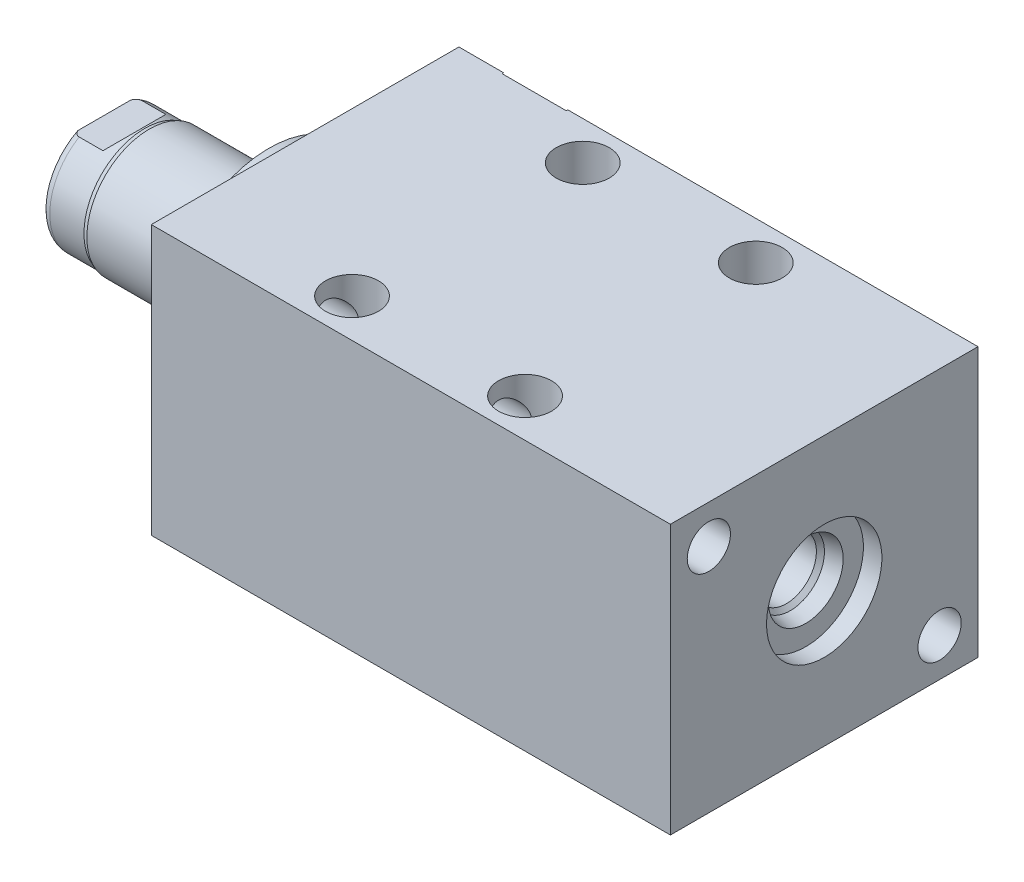
from build123d import *

# Parameters (mm, degrees)
SKETCH1_W          = 50.8
SKETCH1_H          = 44.45
EXTRUDE1_DEPTH     = 85.725
SKETCH5_R          = 17.4625
EXTRUDE2_DEPTH     = 5.969
SKETCH6_W          = 10.31875
SKETCH6_H          = 27.178
CUT_EXTRUDE4_DEPTH = 30.48
HOLE1_D            = 7.1374
HOLE1_DEPTH        = 85.725
HOLE2_D            = 8.7376
HOLE2_DEPTH        = 44.45
LPATTERN1_COUNT    = 2
LPATTERN1_PITCH    = 28.575


with BuildPart() as part:
    # Sketch1 → Extrude1 (new body)
    with BuildSketch(Plane(origin=(0, 0, 0), x_dir=(0, 0, -1), z_dir=(1, 0, 0))):
        Rectangle(SKETCH1_W, SKETCH1_H)
    extrude(amount=EXTRUDE1_DEPTH)

    # S2D0002 → Cut-Revolve1 (revolve, cut)
    with BuildSketch(Plane(origin=(0, 14.3002, 0), x_dir=(-1, 0, 0), z_dir=(0, 1, 0)), mode=Mode.PRIVATE) as cut_revolve1_sk:
        Polygon((-18.8849, -25.146), (-22.225, -25.146), (-22.225, -25.4), (-12.7, -25.4), (-12.7, -11.176), (-17.6784, -11.176), (-17.6784, -21.929393135), (-18.342306865, -22.5933), align=None)
    revolve(cut_revolve1_sk.sketch.rotate(Axis((12.7, 14.3002, -19.13842003), (0, 0, 1)), 180), axis=Axis((12.7, 14.3002, -19.13842003), (0, 0, 1)), mode=Mode.SUBTRACT)  # turned: the seam where the file's is

    # Sketch3 → Cut-Revolve2 (revolve, cut)
    with BuildSketch(Plane(origin=(41.148, 0, -25.146), x_dir=(1, 0, 0), z_dir=(0, 1, 0))):
        Polygon((34.8869, 0), (38.227, 0), (38.227, 0.254), (28.702, 0.254), (28.702, -13.97), (33.6804, -13.97), (33.6804, -3.216606865), (34.344306865, -2.5527), align=None)
    revolve(axis=Axis((69.85, 0, -3.189624441), (0, 0, -1)), mode=Mode.SUBTRACT)

    # Sketch4 → Cut-Revolve3 (revolve, cut)
    with BuildSketch(Plane(origin=(53.975, 0, 0), x_dir=(0, -1, 0), z_dir=(0, 0, 1)), mode=Mode.PRIVATE) as cut_revolve3_sk:
        Polygon((6.1849, 28.702), (9.525, 28.702), (9.525, 31.75), (0, 31.75), (0, 17.3482), (4.9784, 17.3482), (4.9784, 25.485393135), (5.642306865, 26.1493), align=None)
    revolve(cut_revolve3_sk.sketch.rotate(Axis((38.879609832, 0, 0), (1, 0, 0)), 270), axis=Axis((38.879609832, 0, 0), (1, 0, 0)), mode=Mode.SUBTRACT)  # turned: the seam where the file's is

    # Sketch5 → Extrude2 (add)
    with BuildSketch(Plane.ZY):
        Circle(SKETCH5_R)
    extrude(amount=EXTRUDE2_DEPTH)

    # Sketch6 → Revolve1 (revolve)
    with BuildSketch(Plane(origin=(0, 0, 0), x_dir=(0, 0, 1), z_dir=(0, -1, 0)), mode=Mode.PRIVATE) as revolve1_sk:
        with Locations((-5.159375, 19.558)):
            Rectangle(SKETCH6_W, SKETCH6_H)
    revolve(revolve1_sk.sketch.rotate(Axis((5.754582971, 0, 0), (-1, 0, 0)), 180), axis=Axis((5.754582971, 0, 0), (-1, 0, 0)))  # turned: the seam where the file's is

    # S2D0001 → Cut-Revolve4 (revolve, cut)
    with BuildSketch(Plane(origin=(-18.511260017, 3.2639, 0), x_dir=(0, 1, 0), z_dir=(0, 0, 1)), mode=Mode.PRIVATE) as cut_revolve4_sk:
        Polygon((0, 12.7), (0, -0.299460017), (-3.2639, -0.299460017), (-3.2639, 14.635739983), (1.1176, 14.635739983), align=None)
    revolve(cut_revolve4_sk.sketch.rotate(Axis((0, 0, 0), (-1, 0, 0)), 270), axis=Axis((0, 0, 0), (-1, 0, 0)), mode=Mode.SUBTRACT)  # turned: the seam where the file's is

    # Sketch8 → Cut-Revolve5 (revolve, cut)
    with BuildSketch(Plane(origin=(0, 0, 0), x_dir=(0, 0, -1), z_dir=(0, 1, 0)), mode=Mode.PRIVATE) as cut_revolve5_sk:
        with BuildLine():
            Line((-10.31875, 25.7302), (-10.033, 26.4922))
            Line((-10.033, 26.4922), (-10.033, 32.131))
            ThreePointArc((-10.033, 32.131), (-9.932678675, 32.674796865), (-9.644922533, 33.147))
            Line((-9.644922533, 33.147), (-10.31875, 33.147))
            Line((-10.31875, 33.147), (-10.31875, 25.7302))
        make_face()
    revolve(cut_revolve5_sk.sketch.rotate(Axis((-12.65936, 0, 0), (-1, 0, 0)), 180), axis=Axis((-12.65936, 0, 0), (-1, 0, 0)), mode=Mode.SUBTRACT)  # turned: the seam where the file's is

    # Sketch12 → Cut-Extrude4 (cut, symmetric)
    with BuildSketch(Plane(origin=(0, 0, 0), x_dir=(0, -1, 0), z_dir=(0, 0, -1))):
        Polygon((8.5852, 33.147), (8.5852, 28.194), (10.033, 26.7462), (10.033, 33.147), align=None)
        Polygon((-8.5852, 33.147), (-8.5852, 28.194), (-10.033, 26.7462), (-10.033, 33.147), align=None)
    extrude(amount=CUT_EXTRUDE4_DEPTH, both=True, mode=Mode.SUBTRACT)

    # Hole1
    with Locations(Plane.ZY):
        with Locations((-19.05, -15.875), (19.05, 15.875)):
            Hole(HOLE1_D / 2, depth=HOLE1_DEPTH)

    # Hole2
    with Locations(Plane(origin=(0, 22.225, 0), x_dir=(-1, 0, 0), z_dir=(0, 1, 0))):
        with Locations((-26.797, -19.05), (-26.797, 19.05)):
            hole2 = Hole(HOLE2_D / 2, depth=HOLE2_DEPTH)

    # LPattern1: Hole2 ×2
    with Locations(*[(i * LPATTERN1_PITCH, 0, 0) for i in range(1, LPATTERN1_COUNT)]):
        add(hole2, mode=Mode.SUBTRACT)


solid = part.part
